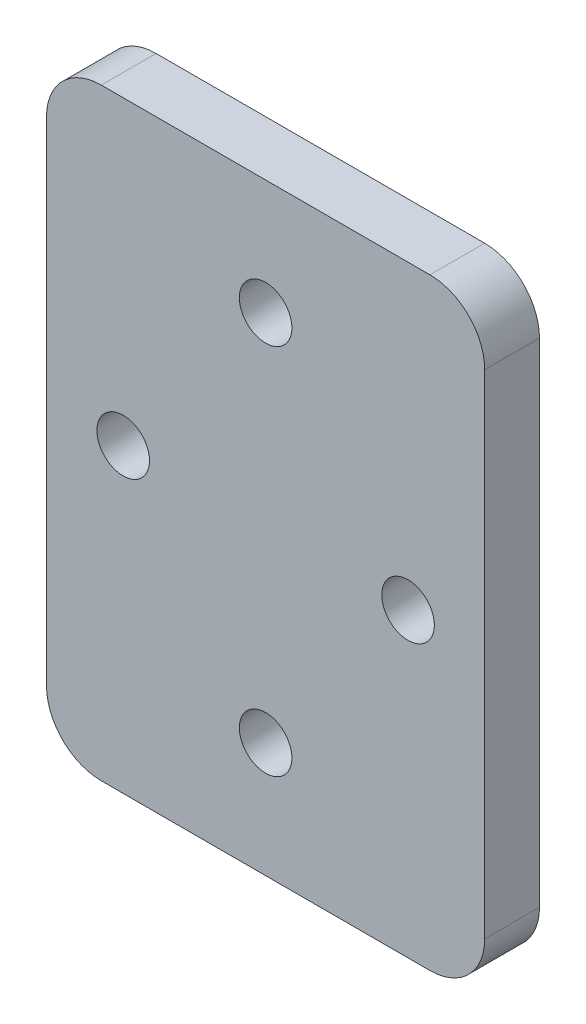
from build123d import *

# Parameters (mm, degrees)
SKETCH1_W           = 40
SKETCH1_H           = 55
SKETCH1_R           = 2.4
BOSS_EXTRUDE1_DEPTH = 5
FILLET1_R           = 5


with BuildPart() as part:
    # Sketch1 → Boss-Extrude1 (new body)
    with BuildSketch(Plane.XY):
        Rectangle(SKETCH1_W, SKETCH1_H)
        with Locations((0, 17)):
            Circle(SKETCH1_R, mode=Mode.SUBTRACT)
        with Locations((-13, 0)):
            Circle(SKETCH1_R, mode=Mode.SUBTRACT)
        with Locations((0, -17)):
            Circle(SKETCH1_R, mode=Mode.SUBTRACT)
        with Locations((13, 0)):
            Circle(SKETCH1_R, mode=Mode.SUBTRACT)
    extrude(amount=BOSS_EXTRUDE1_DEPTH)

    # Fillet1
    fillet1_edges = [part.edges().sort_by_distance(p)[0] for p in [
        (20, -27.5, 2.5),
        (-20, -27.5, 2.5),
        (-20, 27.5, 2.5),
        (20, 27.5, 2.5),
    ]]
    fillet(fillet1_edges, radius=FILLET1_R)


solid = part.part
